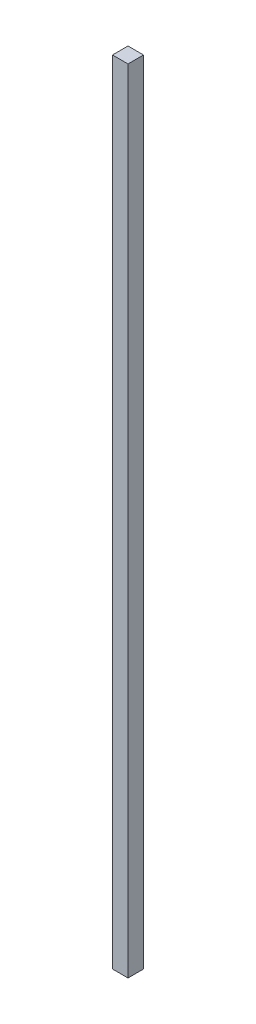
from build123d import *

# Parameters (mm, degrees)
SKETCH1_W           = 5
SKETCH1_H           = 5
BOSS_EXTRUDE1_DEPTH = 255


with BuildPart() as part:
    # Sketch1 → Boss-Extrude1 (new body)
    with BuildSketch(Plane(origin=(0, 0, 0), x_dir=(1, 0, 0), z_dir=(0, 1, 0))):
        Rectangle(SKETCH1_W, SKETCH1_H)
    extrude(amount=BOSS_EXTRUDE1_DEPTH)


solid = part.part
